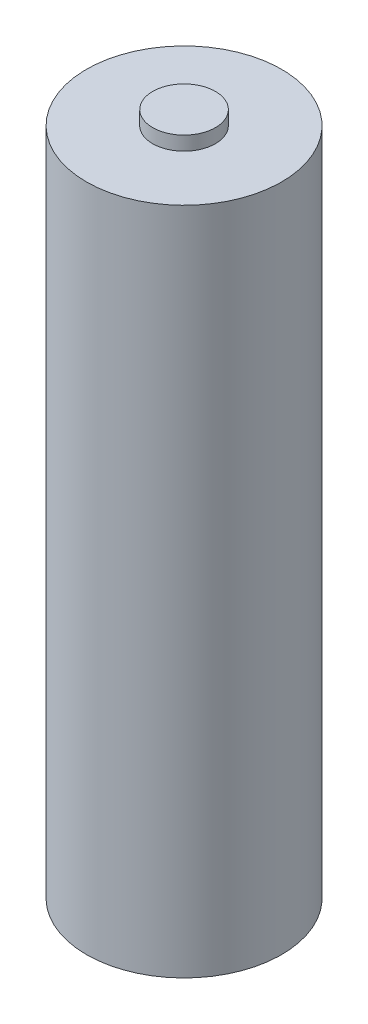
from build123d import *

# Parameters (mm, degrees)
SKETCH1_R           = 7
BOSS_EXTRUDE1_DEPTH = 48
SKETCH2_R           = 2.25
BOSS_EXTRUDE2_DEPTH = 1
SKETCH3_R           = 4.5
BOSS_EXTRUDE3_DEPTH = 0.5
SKETCH4_R           = 3
SKETCH4_R_2         = 2.5
CUT_EXTRUDE1_DEPTH  = 1.5


with BuildPart() as part:
    # Sketch1 → Boss-Extrude1 (new body)
    with BuildSketch(Plane(origin=(0, 0, 0), x_dir=(1, 0, 0), z_dir=(0, 1, 0))):
        Circle(SKETCH1_R)
    extrude(amount=BOSS_EXTRUDE1_DEPTH)

    # Sketch2 → Boss-Extrude2 (add)
    with BuildSketch(Plane(origin=(0, 48, 0), x_dir=(1, 0, 0), z_dir=(0, 1, 0))):
        Circle(SKETCH2_R)
    extrude(amount=BOSS_EXTRUDE2_DEPTH)

    # Sketch3 → Boss-Extrude3 (add)
    with BuildSketch(Plane(origin=(0, 0, 0), x_dir=(1, 0, 0), z_dir=(0, 1, 0))):
        Circle(SKETCH3_R)
    extrude(amount=-BOSS_EXTRUDE3_DEPTH)

    # Sketch4 → Cut-Extrude1 (cut, through all)
    with BuildSketch(Plane(origin=(0, 0, 0), x_dir=(1, 0, 0), z_dir=(0, 1, 0))):
        Circle(SKETCH4_R)
        Circle(SKETCH4_R_2, mode=Mode.SUBTRACT)
    extrude(amount=-CUT_EXTRUDE1_DEPTH, mode=Mode.SUBTRACT)


solid = part.part
